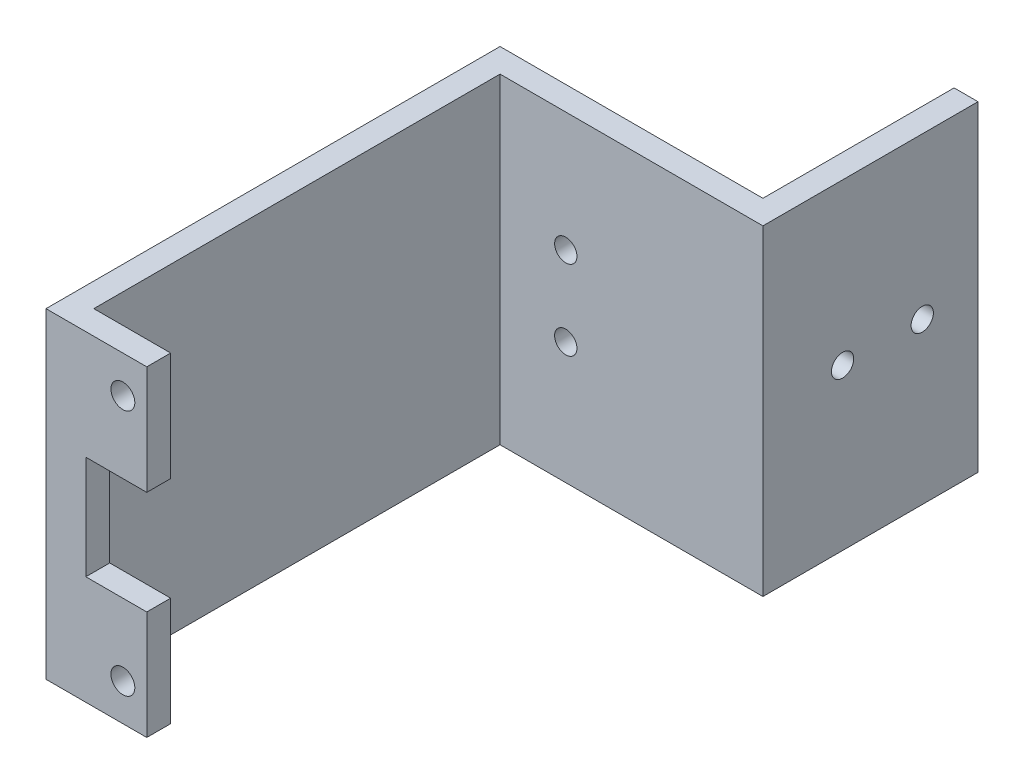
from build123d import *

# Parameters (mm, degrees)
SKETCH1_R           = 1.5
BOSS_EXTRUDE1_DEPTH = 3
SKETCH2_W           = 51
SKETCH2_H           = 40.3
BOSS_EXTRUDE2_DEPTH = 3
SKETCH3_W           = 33
SKETCH3_H           = 40.3
SKETCH3_R           = 1.4
BOSS_EXTRUDE3_DEPTH = 3
SKETCH5_W           = 27
SKETCH5_H           = 40.3
SKETCH5_R           = 1.4
BOSS_EXTRUDE4_DEPTH = 3


with BuildPart() as part:
    # Sketch1 → Boss-Extrude1 (new body)
    with BuildSketch(Plane.XY):
        Polygon((-28.851027023, -20.15), (-28.851027023, -13), (-28.851027023, -6.5), (-36.501027023, -6.5), (-36.501027023, -16.735786438), (-33.086813461, -20.15), align=None)
        with Locations((-31.851027023, -15.5)):
            Circle(SKETCH1_R, mode=Mode.SUBTRACT)
        Polygon((-36.501027023, 16.735786438), (-36.501027023, 6.5), (-28.851027023, 6.5), (-28.851027023, 20.15), (-33.086813461, 20.15), align=None)
        with Locations((-31.851027023, 15.5)):
            Circle(SKETCH1_R, mode=Mode.SUBTRACT)
        Polygon((-36.501027023, -20.15), (-33.086813461, -20.15), (-36.501027023, -16.735786438), align=None)
        Polygon((-36.501027023, 20.15), (-36.501027023, 16.735786438), (-33.086813461, 20.15), align=None)
        Polygon((-36.501027023, -16.735786438), (-36.501027023, -6.5), (-36.501027023, 6.5), (-36.501027023, 16.735786438), (-36.501027023, 20.15), (-41.501027023, 20.15), (-41.501027023, -20.15), (-36.501027023, -20.15), align=None)
    extrude(amount=BOSS_EXTRUDE1_DEPTH)

    # Sketch2 → Boss-Extrude2 (add)
    with BuildSketch(Plane(origin=(-41.501027023, 0, 0), x_dir=(0, 0, -1), z_dir=(1, 0, 0))):
        with Locations((25.5, 0)):
            Rectangle(SKETCH2_W, SKETCH2_H)
    extrude(amount=BOSS_EXTRUDE2_DEPTH)

    # Sketch3 → Boss-Extrude3 (add)
    with BuildSketch(Plane(origin=(0, 0, -51), x_dir=(-1, 0, 0), z_dir=(0, 0, -1))):
        with Locations((25.001027023, 0)):
            Rectangle(SKETCH3_W, SKETCH3_H)
        with Locations((30.251027023, 5.15)):
            Circle(SKETCH3_R, mode=Mode.SUBTRACT)
        with Locations((30.251027023, -4.85)):
            Circle(SKETCH3_R, mode=Mode.SUBTRACT)
    extrude(amount=BOSS_EXTRUDE3_DEPTH)

    # Sketch5 → Boss-Extrude4 (add)
    with BuildSketch(Plane(origin=(-8.501027023, 0, 0), x_dir=(0, 0, -1), z_dir=(1, 0, 0))):
        with Locations((64.5, 0)):
            Rectangle(SKETCH5_W, SKETCH5_H)
        with Locations((71, 0)):
            Circle(SKETCH5_R, mode=Mode.SUBTRACT)
        with Locations((61, 0)):
            Circle(SKETCH5_R, mode=Mode.SUBTRACT)
    extrude(amount=BOSS_EXTRUDE4_DEPTH)


solid = part.part
